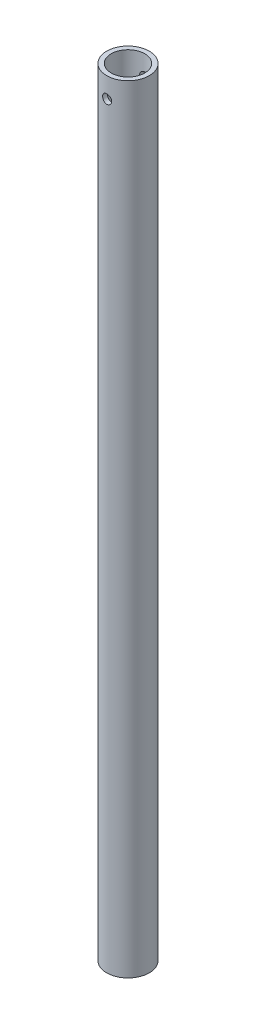
from build123d import *

# Parameters (mm, degrees)
SWEEP1_PROFILE_R        = 16.7005
SHELL1_T                = -3.556
F_1_4_CLEARANCE_HOLE4_D = 7.14248


with BuildPart() as part:
    # Sweep1: sweep along a path in Sketch2
    with BuildLine(Plane(origin=(0, 0, 0), x_dir=(0, 0, -1), z_dir=(1, 0, 0))) as sweep1_path:
        Line((0, 0), (0, 609.6))
    # Sweep1 profile (on start of the path) → Sweep1 (sweep)
    with BuildSketch(Plane.ZX):
        Circle(SWEEP1_PROFILE_R)
    sweep(path=sweep1_path.line)

    # Shell1
    shell1_openings = [part.faces().sort_by_distance(p)[0] for p in [
        (0, 609.6, 16.7005),
        (0, 0, 16.7005),
    ]]
    offset(amount=SHELL1_T, openings=shell1_openings, kind=Kind.INTERSECTION)

    # 1/4 Clearance Hole4 (through all)
    with Locations(Plane.XY.offset(16.7005)):
        with Locations((0, 593.725)):
            Hole(F_1_4_CLEARANCE_HOLE4_D / 2)


solid = part.part
